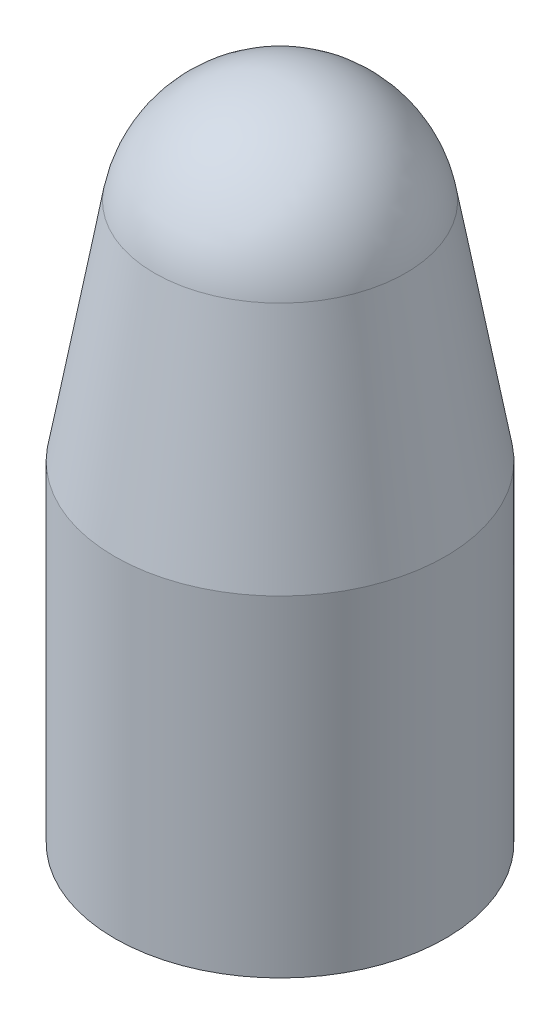
from build123d import *

# Parameters (mm, degrees)
SKETCH1_R                     = 5
BOSS_EXTRUDE1_DEPTH           = 10
BOSS_EXTRUDE1_OTHER_WAY_DEPTH = 10
BOSS_EXTRUDE1_OTHER_WAY_TAPER = 10
FILLET1_R                     = 3.85
SHELL1_T                      = -2.5


with BuildPart() as part:
    # Sketch1 → Boss-Extrude1 (new body)
    with BuildSketch(Plane(origin=(0, 0, 0), x_dir=(1, 0, 0), z_dir=(0, 1, 0))):
        with Locations(Location((0, 0, 0), (0, 0, 270))):
            Circle(SKETCH1_R)
    extrude(amount=-BOSS_EXTRUDE1_DEPTH)

    # Sketch1 → Boss-Extrude1 other way (add)
    with BuildSketch(Plane(origin=(0, 0, 0), x_dir=(1, 0, 0), z_dir=(0, 1, 0))):
        with Locations(Location((0, 0, 0), (0, 0, 270))):
            Circle(SKETCH1_R)
    extrude(amount=BOSS_EXTRUDE1_OTHER_WAY_DEPTH, taper=BOSS_EXTRUDE1_OTHER_WAY_TAPER)

    # Fillet1
    fillet1_edges = [part.edges().sort_by_distance(p)[0] for p in [
        (0, 10, -3.236730193),
    ]]
    fillet(fillet1_edges, radius=FILLET1_R)

    # Shell1
    shell1_openings = [part.faces().sort_by_distance(p)[0] for p in [
        (0, -10, 0),
    ]]
    offset(amount=SHELL1_T, openings=shell1_openings, kind=Kind.INTERSECTION)


solid = part.part
